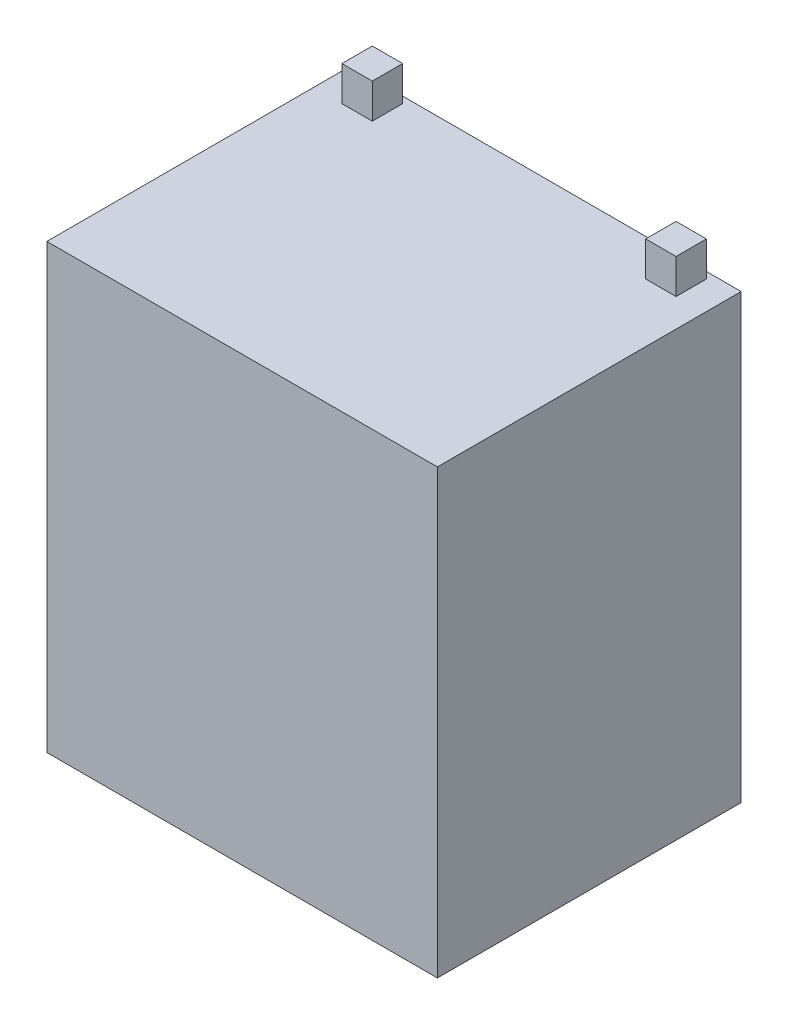
from build123d import *

# Parameters (mm, degrees)
ESQUISSE1_W        = 90
ESQUISSE1_H        = 70
BOSS_EXTRU_1_DEPTH = 102
ESQUISSE2_W        = 7
ESQUISSE2_H        = 7
BOSS_EXTRU_2_DEPTH = 8


with BuildPart() as part:
    # Esquisse1 → Boss.-Extru.1 (new body)
    with BuildSketch(Plane(origin=(0, 0, 0), x_dir=(1, 0, 0), z_dir=(0, 1, 0))):
        Rectangle(ESQUISSE1_W, ESQUISSE1_H)
    extrude(amount=BOSS_EXTRU_1_DEPTH)

    # Esquisse2 → Boss.-Extru.2 (add)
    with BuildSketch(Plane(origin=(0, 102, 0), x_dir=(1, 0, 0), z_dir=(0, 1, 0))):
        with Locations((35, 30)):
            Rectangle(ESQUISSE2_W, ESQUISSE2_H)
        with Locations((-35, 30)):
            Rectangle(ESQUISSE2_W, ESQUISSE2_H)
    extrude(amount=BOSS_EXTRU_2_DEPTH)


solid = part.part
